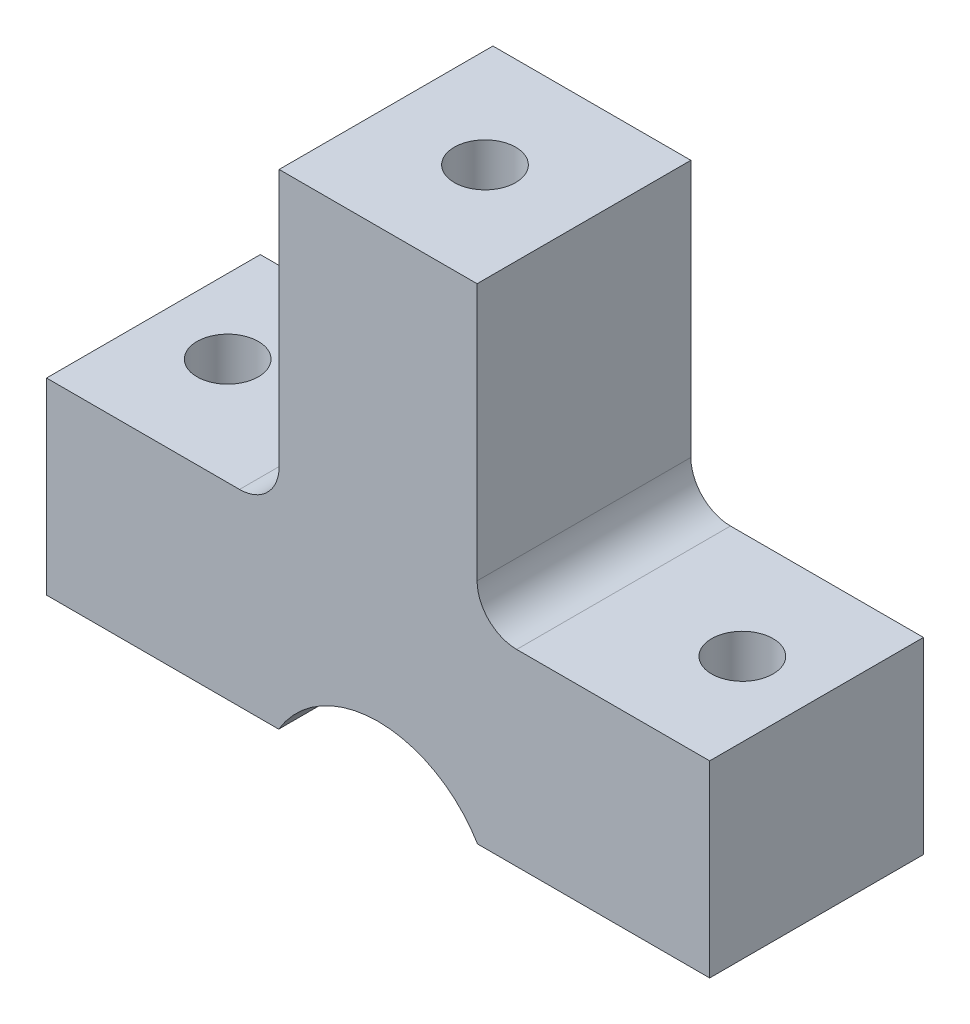
from build123d import *

# Parameters (mm, degrees)
SKETCH1_W           = 33.5
SKETCH1_H           = 9.5
BOSS_EXTRUDE1_DEPTH = 10.8
CUT_EXTRUDE1_START  = -5
SKETCH2_R           = 6.05
CUT_EXTRUDE1_DEPTH  = 5
CUT_EXTRUDE2_START  = -3.8
SKETCH4_R           = 8.05
CUT_EXTRUDE2_DEPTH  = 3.8
SKETCH5_R           = 1.55
CUT_EXTRUDE3_DEPTH  = 10.5
SKETCH6_W           = 10
SKETCH6_H           = 10.8
BOSS_EXTRUDE2_DEPTH = 15
SKETCH7_R           = 1.55
CUT_EXTRUDE4_DEPTH  = 3
CUT_EXTRUDE5_DEPTH  = 2.75
FILLET1_R           = 2
BOSS_EXTRUDE3_DEPTH = 5
BOSS_EXTRUDE4_REACH = 10.8


with BuildPart() as part:
    # Sketch1 → Boss-Extrude1 (new body)
    with BuildSketch(Plane.XY):
        with Locations((4.4, -4.75)):
            Rectangle(SKETCH1_W, SKETCH1_H)
    extrude(amount=BOSS_EXTRUDE1_DEPTH)

    # Sketch2 → Cut-Extrude1 (cut)
    with BuildSketch(Plane.XY.offset(10.8).offset(CUT_EXTRUDE1_START)):
        with Locations((4.4, -12.5)):
            Circle(SKETCH2_R)
    extrude(amount=CUT_EXTRUDE1_DEPTH, mode=Mode.SUBTRACT)

    # Sketch4 → Cut-Extrude2 (cut)
    with BuildSketch(Plane.XY.offset(5.8).offset(CUT_EXTRUDE2_START)):
        with Locations((4.4, -12.5)):
            Circle(SKETCH4_R)
    extrude(amount=CUT_EXTRUDE2_DEPTH, mode=Mode.SUBTRACT)

    # Sketch5 → Cut-Extrude3 (cut, through all)
    with BuildSketch(Plane(origin=(0, 0, 0), x_dir=(1, 0, 0), z_dir=(0, 1, 0))):
        with Locations((17.4, -5.4)):
            Circle(SKETCH5_R)
        with Locations((-8.6, -5.4)):
            Circle(SKETCH5_R)
    extrude(amount=-CUT_EXTRUDE3_DEPTH, mode=Mode.SUBTRACT)

    # Sketch6 → Boss-Extrude2 (add)
    with BuildSketch(Plane(origin=(0, 0, 0), x_dir=(1, 0, 0), z_dir=(0, 1, 0))):
        with Locations((4.4, -5.4)):
            Rectangle(SKETCH6_W, SKETCH6_H)
    extrude(amount=BOSS_EXTRUDE2_DEPTH)

    # Sketch7 → Cut-Extrude4 (cut)
    with BuildSketch(Plane(origin=(0, 15, 0), x_dir=(1, 0, 0), z_dir=(0, 1, 0))):
        with Locations((4.4, -5.4)):
            Circle(SKETCH7_R)
    extrude(amount=-CUT_EXTRUDE4_DEPTH, mode=Mode.SUBTRACT)

    # Sketch8 → Cut-Extrude5 (cut)
    with BuildSketch(Plane(origin=(0, 12, 0), x_dir=(1, 0, 0), z_dir=(0, 1, 0))):
        Polygon((1.55, 0), (7.25, 0), (7.25, -3.754551733), (7.25, -7.045448267), (4.4, -8.690896534), (1.55, -7.045448267), (1.55, -3.754551733), align=None)
    extrude(amount=-CUT_EXTRUDE5_DEPTH, mode=Mode.SUBTRACT)

    # Fillet1
    fillet1_edges = [part.edges().sort_by_distance(p)[0] for p in [
        (9.4, 0, 5.4),
        (-0.6, 0, 5.4),
    ]]
    fillet(fillet1_edges, radius=FILLET1_R)

    # Sketch9 → Boss-Extrude3 (add)
    with BuildSketch(Plane.XY.offset(10.8)):
        with BuildLine():
            Line((9.653808143, -9.5), (9.422200713, -9.5))
            ThreePointArc((9.422200713, -9.5), (4.4, -6.65), (-0.622200713, -9.5))
            Line((-0.622200713, -9.5), (-0.853808143, -9.5))
            ThreePointArc((-0.853808143, -9.5), (4.4, -6.45), (9.653808143, -9.5))
        make_face()
    extrude(amount=-BOSS_EXTRUDE3_DEPTH)

    # Sketch10 → Boss-Extrude4 (add, up to next)
    with BuildSketch(Plane.XY.offset(2), mode=Mode.PRIVATE) as boss_extrude4_sk1:
        with BuildLine():
            Line((11.870107094, -9.5), (11.654136751, -9.5))
            ThreePointArc((11.654136751, -9.5), (4.4, -4.65), (-2.854136751, -9.5))
            Line((-2.854136751, -9.5), (-3.070107094, -9.5))
            ThreePointArc((-3.070107094, -9.5), (4.4, -4.45), (11.870107094, -9.5))
        make_face()
    boss_extrude4_tool1 = extrude(boss_extrude4_sk1.sketch, amount=BOSS_EXTRUDE4_REACH, mode=Mode.PRIVATE) - part.part
    add(boss_extrude4_tool1.solids().sort_by_distance((11.762122, -9.342294, 2))[0])


solid = part.part
